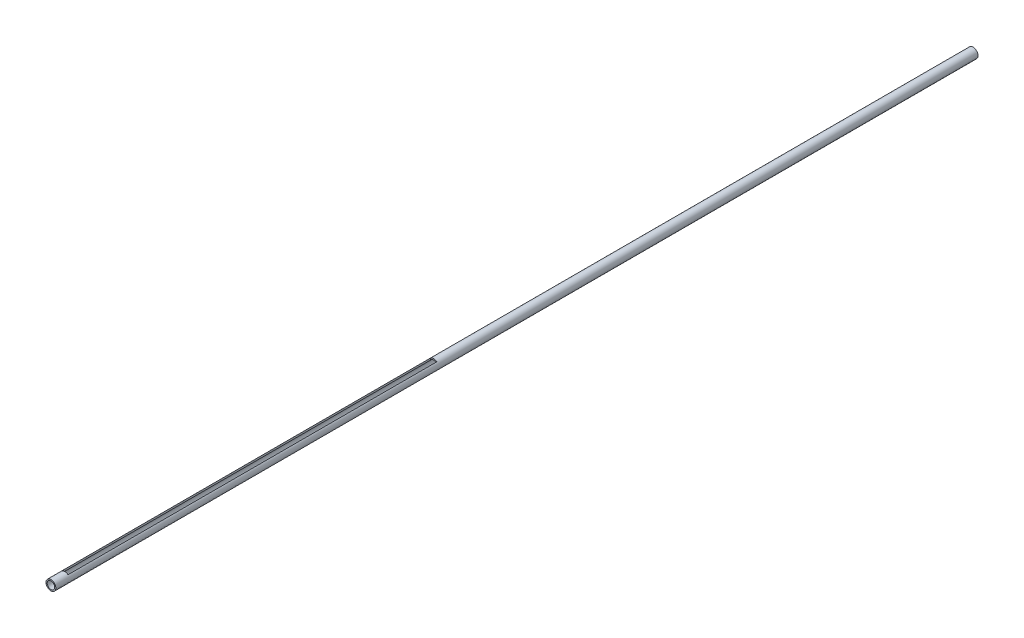
from build123d import *

# Parameters (mm, degrees)
SKETCH1_R           = 0.535
SKETCH1_R_2         = 0.405
BOSS_EXTRUDE1_DEPTH = 100
SKETCH2_W           = 0.7
SKETCH2_H           = 40
CUT_EXTRUDE1_DEPTH  = 101.002862209


with BuildPart() as part:
    # Sketch1 → Boss-Extrude1 (new body)
    with BuildSketch(Plane.XY):
        Circle(SKETCH1_R)
        Circle(SKETCH1_R_2, mode=Mode.SUBTRACT)
    extrude(amount=BOSS_EXTRUDE1_DEPTH)

    # Sketch2 → Cut-Extrude1 (cut, through all)
    with BuildSketch(Plane(origin=(0, 0, 0), x_dir=(1, 0, 0), z_dir=(0, 1, 0))):
        with Locations((0, -78.5)):
            Rectangle(SKETCH2_W, SKETCH2_H)
    extrude(amount=CUT_EXTRUDE1_DEPTH, mode=Mode.SUBTRACT)


solid = part.part
